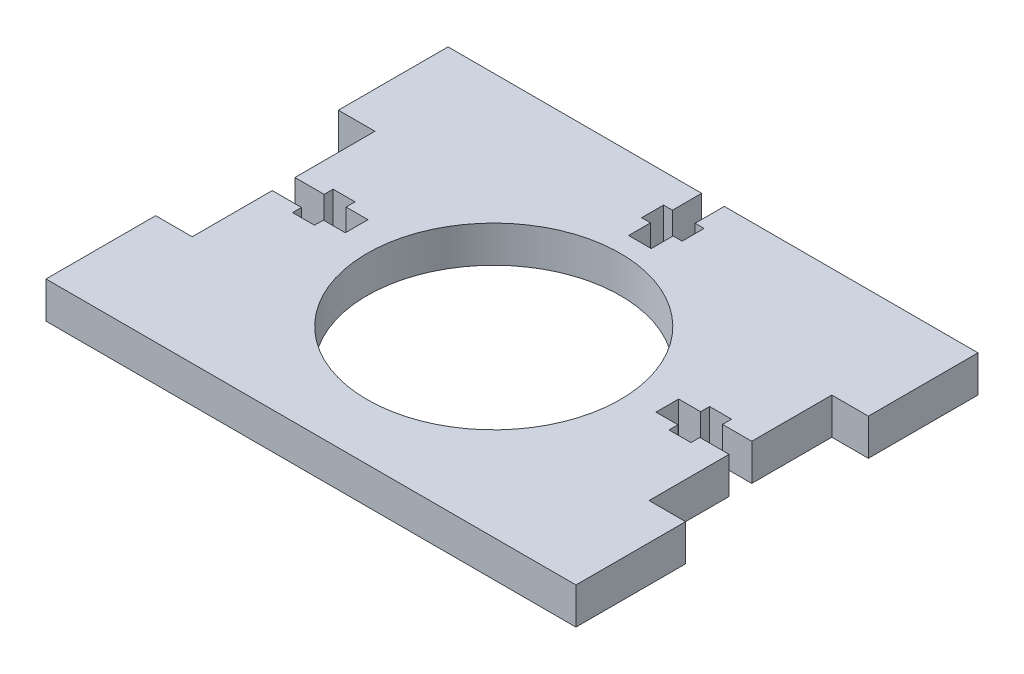
from build123d import *

# Parameters (mm, degrees)
ESQUISSE1_W             = 26.25
ESQUISSE1_H             = 55
BOSS_EXTRU_1_DEPTH      = 5
BOSS_EXTRU_2_DEPTH      = 5
BOSS_EXTRU_3_DEPTH      = 5
ENL_V_MAT_EXTRU_1_DEPTH = 5
ESQUISSE5_W             = 50
ESQUISSE5_H             = 5
BOSS_EXTRU_4_DEPTH      = 36.25
BOSS_EXTRU_5_DEPTH      = 5
BOSS_EXTRU_6_DEPTH      = 5
BOSS_EXTRU_7_DEPTH      = 5
D_GAGEMENT_M301_D       = 34.65
D_GAGEMENT_M301_DEPTH   = 5
CONG_1_R                = 1.6
ESQUISSE11_W            = 20.033305553
ESQUISSE11_H            = 6.190231364
ESQUISSE11_W_2          = 5
ESQUISSE11_H_2          = 2.95
BOSS_EXTRU_8_DEPTH      = 5
ESQUISSE12_W            = 3.1
ESQUISSE12_H            = 4
ESQUISSE12_H_2          = 3
ESQUISSE12_W_2          = 1.23
ESQUISSE12_W_3          = 1.22
ESQUISSE12_W_4          = 4
ESQUISSE12_H_3          = 3.1
ESQUISSE12_W_5          = 3
ESQUISSE12_H_4          = 1.23
ESQUISSE12_H_5          = 1.22
ENL_V_MAT_EXTRU_2_DEPTH = 6


with BuildPart() as part:
    # Esquisse1 → Boss.-Extru.1 (new body)
    with BuildSketch(Plane(origin=(0, 5, 0), x_dir=(1, 0, 0), z_dir=(0, 1, 0))):
        with Locations((18.125, 0)):
            Rectangle(ESQUISSE1_W, ESQUISSE1_H)
    extrude(amount=-BOSS_EXTRU_1_DEPTH)

    # Esquisse2 → Boss.-Extru.2 (add)
    with BuildSketch(Plane(origin=(31.25, 0, 0), x_dir=(0, 0, -1), z_dir=(1, 0, 0))):
        Polygon((27.5, 5), (27.5, 0), (15.45, 0), (12.5, 2.95), (12.5, 5), align=None)
    extrude(amount=BOSS_EXTRU_2_DEPTH)

    # Esquisse3 → Boss.-Extru.3 (add)
    with BuildSketch(Plane(origin=(31.25, 0, 0), x_dir=(0, 0, -1), z_dir=(1, 0, 0))):
        Polygon((-15.45, 0), (-27.5, 0), (-27.5, 5), (-12.5, 5), (-12.5, 2.95), align=None)
    extrude(amount=BOSS_EXTRU_3_DEPTH)

    # Esquisse4 → Enlèv. mat.-Extru.1 (cut)
    with BuildSketch(Plane(origin=(0, 0, -27.5), x_dir=(-1, 0, 0), z_dir=(0, 0, -1))):
        Polygon((-5, 0), (-5, 2.95), (-7.95, 0), align=None)
    extrude(amount=-ENL_V_MAT_EXTRU_1_DEPTH, mode=Mode.SUBTRACT)

    # Esquisse5 → Boss.-Extru.4 (add)
    with BuildSketch(Plane.ZY.offset(-5)):
        with Locations((2.5, 2.5)):
            Rectangle(ESQUISSE5_W, ESQUISSE5_H)
    extrude(amount=BOSS_EXTRU_4_DEPTH)

    # Esquisse6 → Boss.-Extru.5 (add)
    with BuildSketch(Plane.ZY.offset(31.25)):
        Polygon((27.5, 5), (27.5, 0), (15.45, 0), (12.5, 2.95), (12.5, 5), align=None)
    extrude(amount=BOSS_EXTRU_5_DEPTH)

    # Esquisse7 → Boss.-Extru.6 (add)
    with BuildSketch(Plane.ZY.offset(31.25)):
        Polygon((-22.5, 5), (-12.5, 5), (-12.5, 2.95), (-15.45, 0), (-22.5, 0), align=None)
    extrude(amount=BOSS_EXTRU_6_DEPTH)

    # Esquisse8 → Boss.-Extru.7 (add)
    with BuildSketch(Plane(origin=(0, 0, -22.5), x_dir=(-1, 0, 0), z_dir=(0, 0, -1))):
        Polygon((5, 2.95), (5, 5), (36.25, 5), (36.25, 0), (7.95, 0), align=None)
    extrude(amount=BOSS_EXTRU_7_DEPTH)

    # Dégagement M301
    with Locations(Plane(origin=(0, 5, 0), x_dir=(1, 0, 0), z_dir=(0, 1, 0))):
        with Locations((0, -2.5)):
            Hole(D_GAGEMENT_M301_D / 2, depth=D_GAGEMENT_M301_DEPTH)

    # Congé1
    cong_1_edges = [part.edges().sort_by_distance(p)[0] for p in [
        (-5, 2.95, -25),
        (33.75, 2.95, -12.5),
        (33.75, 2.95, 12.5),
        (5, 2.95, -25),
        (-33.75, 2.95, 12.5),
        (-33.75, 2.95, -12.5),
    ]]
    fillet(cong_1_edges, radius=CONG_1_R)

    # Esquisse11 → Boss.-Extru.8 (add)
    with BuildSketch(Plane.XZ):
        with Locations((0.06715792, -24.404884318)):
            Rectangle(ESQUISSE11_W, ESQUISSE11_H)
        with Locations((-33.75, -13.975)):
            Rectangle(ESQUISSE11_W_2, ESQUISSE11_H_2)
        with Locations((-33.75, 13.975)):
            Rectangle(ESQUISSE11_W_2, ESQUISSE11_H_2)
        with Locations((33.75, 13.975)):
            Rectangle(ESQUISSE11_W_2, ESQUISSE11_H_2)
        with Locations((33.75, -13.975)):
            Rectangle(ESQUISSE11_W_2, ESQUISSE11_H_2)
    extrude(amount=-BOSS_EXTRU_8_DEPTH)

    # Esquisse12 → Enlèv. mat.-Extru.2 (cut, through all)
    with BuildSketch(Plane.XZ):
        with Locations((0, -25.5)):
            Rectangle(ESQUISSE12_W, ESQUISSE12_H)
        with Locations((0, -22)):
            Rectangle(ESQUISSE12_W, ESQUISSE12_H_2)
        with Locations((2.165, -22)):
            Rectangle(ESQUISSE12_W_2, ESQUISSE12_H_2)
        with Locations((0, -19)):
            Rectangle(ESQUISSE12_W, ESQUISSE12_H_2)
        with Locations((-2.16, -22)):
            Rectangle(ESQUISSE12_W_3, ESQUISSE12_H_2)
        with Locations((29.25, 0)):
            Rectangle(ESQUISSE12_W_4, ESQUISSE12_H_3)
        with Locations((25.75, 0)):
            Rectangle(ESQUISSE12_W_5, ESQUISSE12_H_3)
        with Locations((25.75, -2.165)):
            Rectangle(ESQUISSE12_W_5, ESQUISSE12_H_4)
        with Locations((22.75, 0)):
            Rectangle(ESQUISSE12_W_5, ESQUISSE12_H_3)
        with Locations((25.75, 2.16)):
            Rectangle(ESQUISSE12_W_5, ESQUISSE12_H_5)
        with Locations((-22.75, 0)):
            Rectangle(ESQUISSE12_W_5, ESQUISSE12_H_3)
        with Locations((-25.75, 0)):
            Rectangle(ESQUISSE12_W_5, ESQUISSE12_H_3)
        with Locations((-25.75, -2.165)):
            Rectangle(ESQUISSE12_W_5, ESQUISSE12_H_4)
        with Locations((-29.25, 0)):
            Rectangle(ESQUISSE12_W_4, ESQUISSE12_H_3)
        with Locations((-25.75, 2.16)):
            Rectangle(ESQUISSE12_W_5, ESQUISSE12_H_5)
    extrude(amount=-ENL_V_MAT_EXTRU_2_DEPTH, mode=Mode.SUBTRACT)


solid = part.part
